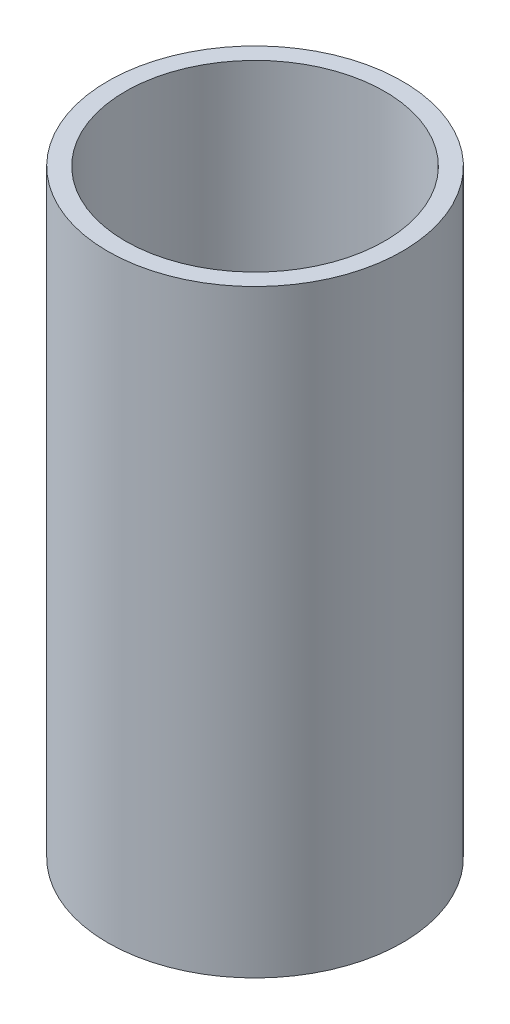
from build123d import *

# Parameters (mm, degrees)
SKETCH1_R           = 25
SKETCH1_R_2         = 22
BOSS_EXTRUDE1_DEPTH = 101.6


with BuildPart() as part:
    # Sketch1 → Boss-Extrude1 (new body)
    with BuildSketch(Plane(origin=(0, 0, 0), x_dir=(1, 0, 0), z_dir=(0, 1, 0))):
        Circle(SKETCH1_R)
        Circle(SKETCH1_R_2, mode=Mode.SUBTRACT)
    extrude(amount=BOSS_EXTRUDE1_DEPTH)


solid = part.part
